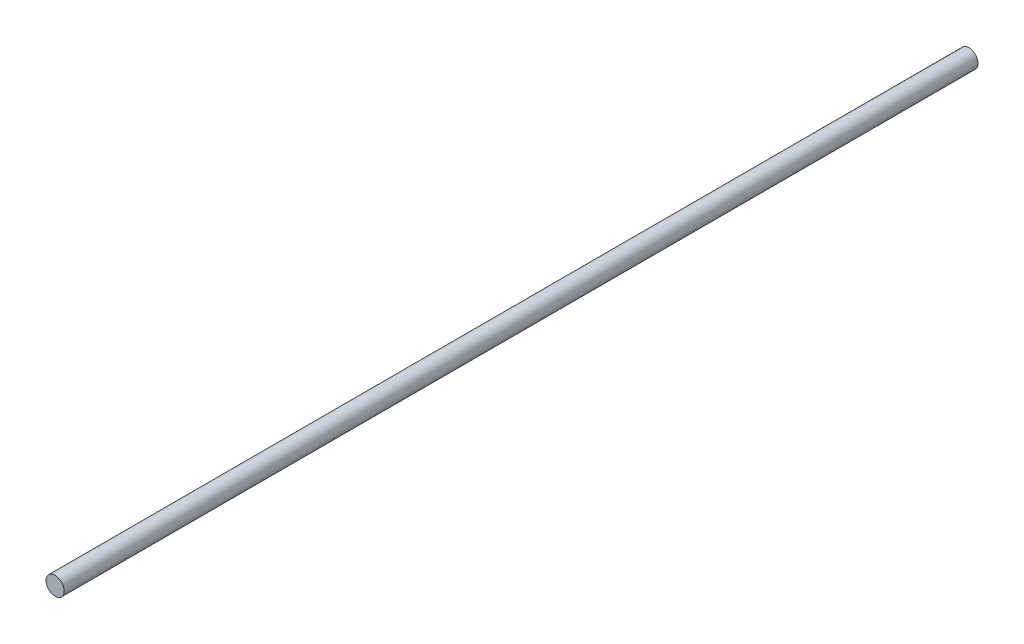
from build123d import *

# Parameters (mm, degrees)
ESBO_O1_R                = 4
RESSALTO_EXTRUS_O1_DEPTH = 201


with BuildPart() as part:
    # Esboço1 → Ressalto-extrusão1 (new, symmetric)
    with BuildSketch(Plane.XY):
        Circle(ESBO_O1_R)
    extrude(amount=RESSALTO_EXTRUS_O1_DEPTH, both=True)


solid = part.part
